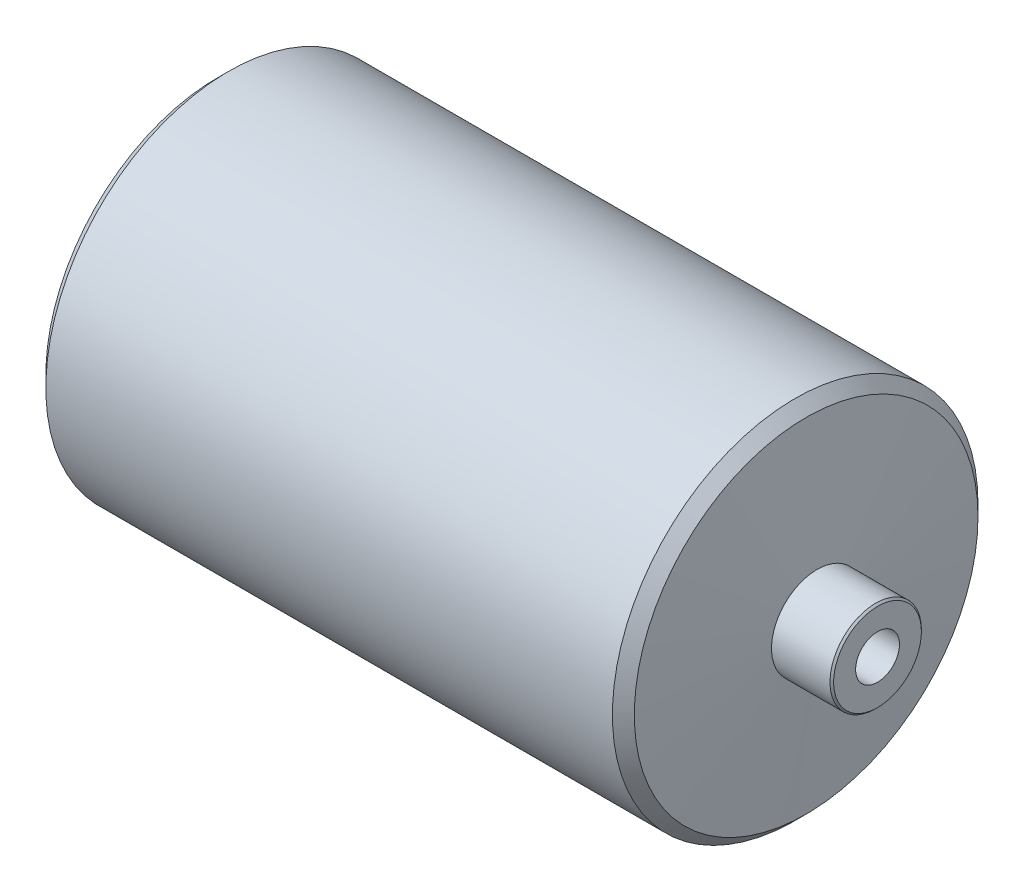
from build123d import *

# Parameters (mm, degrees)
TALADRO_DE_MARGEN_PARA_M102_D     = 12
TALADRO_DE_MARGEN_PARA_M102_DEPTH = 55.394836286
TALADRO_DE_MARGEN_PARA_M102_TIP   = 3.605163714


with BuildPart() as part:
    # Croquis1 → Revolución1 (revolve)
    with BuildSketch(Plane.XY):
        Polygon((100, 0), (100, 12), (99.5, 12.5), (83.5, 12.5), (80.481641108, 47), (77.481641108, 50), (-77.481641108, 50), (-80.481641108, 47), (-83.5, 12.5), (-99.5, 12.5), (-100, 12), (-100, 0), align=None)
    revolve(axis=Axis((112.244897959, 0, 0), (-1, 0, 0)))

    # Croquis8 → Taladro de margen para M101 (revolve, cut)
    with BuildSketch(Plane(origin=(-100, 0, 0), x_dir=(0, 0, 1), z_dir=(0, 1, 0))):
        Polygon((0, 0), (0, 59), (6, 55.394836286), (6, 0), align=None)
    revolve(axis=Axis((-106.35, 0, 0), (1, 0, 0)), mode=Mode.SUBTRACT)

    # Taladro de margen para M102
    with Locations(Plane(origin=(100, 0, 0), x_dir=(0, 0, 1), z_dir=(1, 0, 0))):
        with Locations((0, 0)):
            Hole(TALADRO_DE_MARGEN_PARA_M102_D / 2, depth=TALADRO_DE_MARGEN_PARA_M102_DEPTH)
            with Locations((0, 0, -(TALADRO_DE_MARGEN_PARA_M102_DEPTH + TALADRO_DE_MARGEN_PARA_M102_TIP / 2))):  # 118° drill point
                Cone(0, TALADRO_DE_MARGEN_PARA_M102_D / 2, TALADRO_DE_MARGEN_PARA_M102_TIP, mode=Mode.SUBTRACT)


solid = part.part
